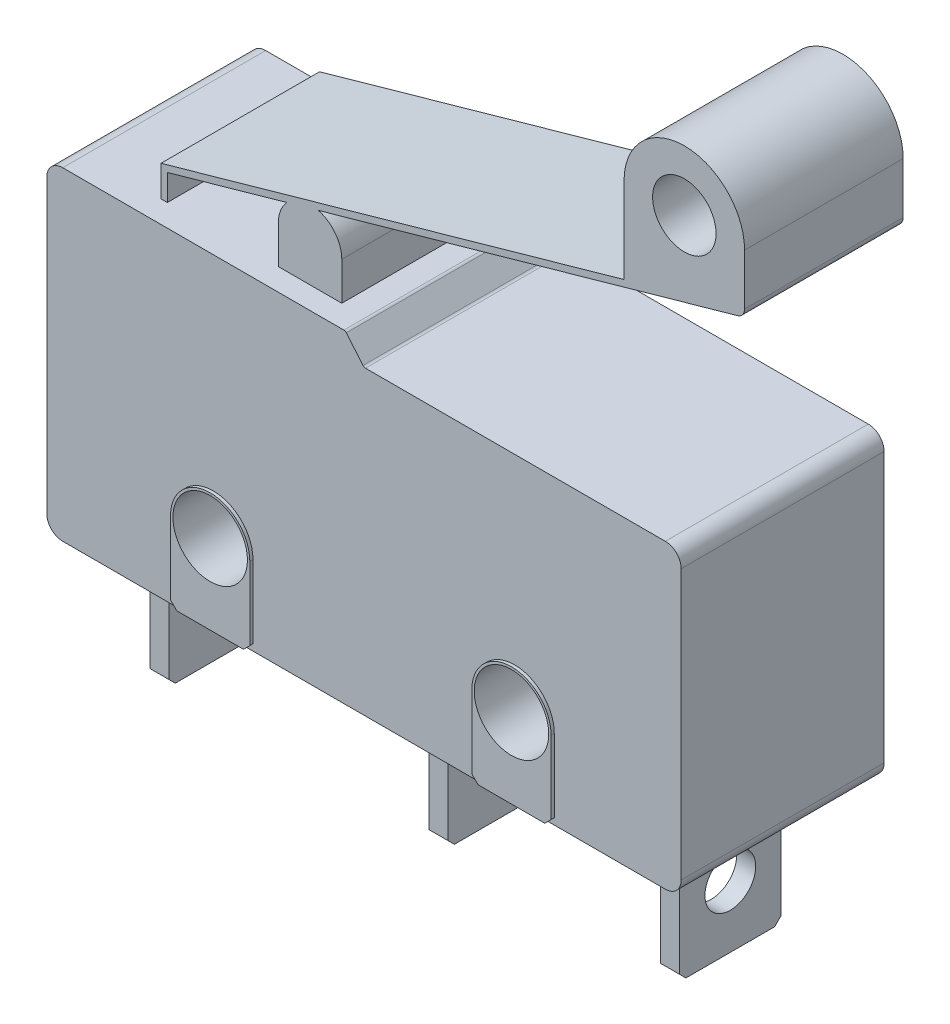
from build123d import *

# Parameters (mm, degrees)
SKETCH_1_W               = 20
SKETCH_1_H               = 10.2
SKETCH_1_R               = 1.175
EXTRUDE_1_DEPTH          = 6.4
CUT_EXTRUDE_1_DEPTH      = 1
CUT_EXTRUDE_1_DEPTH_BACK = 7.4
FILLET_1_R               = 0.1
FILLET_2_R               = 0.5
SKETCH_8_R               = 1.175
EXTRUDE_5_DEPTH          = 0.1
CHAMFER_1_SIZE           = 0.2
SKETCH_3_W               = 0.6
SKETCH_3_H               = 3.9
EXTRUDE_2_DEPTH          = 1.6
SKETCH_9_R               = 0.8
CUT_EXTRUDE_2_DEPTH      = 19.35
CHAMFER_2_SIZE           = 0.2
SKETCH_5_R               = 1
EXTRUDE_3_DEPTH          = 2.5
EXTRUDE_6_DEPTH          = 2.5
FILLET_3_R               = 0.3


with BuildPart() as part:
    # 草图1 → 凸台-拉伸1 (new body)
    with BuildSketch(Plane.XY):
        with Locations((10, 5.1)):
            Rectangle(SKETCH_1_W, SKETCH_1_H)
        with Locations((5.25, 2.5)):
            Circle(SKETCH_1_R, mode=Mode.SUBTRACT)
        with Locations((14.75, 2.5)):
            Circle(SKETCH_1_R, mode=Mode.SUBTRACT)
    extrude(amount=EXTRUDE_1_DEPTH)

    # 草图7 → 切除-拉伸1 (cut, two sides)
    with BuildSketch(Plane.XY.offset(6.4)) as cut_extrude_1_sk:
        Polygon((20, 9.5), (10, 9.5), (9.412630258, 10.2), (20, 10.2), align=None)
    extrude(amount=CUT_EXTRUDE_1_DEPTH, mode=Mode.SUBTRACT)
    extrude(cut_extrude_1_sk.sketch, amount=-CUT_EXTRUDE_1_DEPTH_BACK, mode=Mode.SUBTRACT)

    # 圆角1
    fillet_1_edges = [part.edges().sort_by_distance(p)[0] for p in [
        (9.412630258, 10.2, 3.2),
        (10, 9.5, 3.2),
    ]]
    fillet(fillet_1_edges, radius=FILLET_1_R)

    # 圆角2
    fillet_2_edges = [part.edges().sort_by_distance(p)[0] for p in [
        (20, 9.5, 3.2),
        (0, 10.2, 3.2),
        (20, 0, 3.2),
        (0, 0, 3.2),
    ]]
    fillet(fillet_2_edges, radius=FILLET_2_R)

    # 草图8 → 凸台-拉伸5 (add)
    with BuildSketch(Plane.XY.offset(6.4)):
        with BuildLine():
            Line((4, 2.5), (4, 0))
            Line((4, 0), (6.5, 0))
            Line((6.5, 0), (6.5, 2.5))
            ThreePointArc((6.5, 2.5), (5.25, 3.75), (4, 2.5))
        make_face()
        with Locations((5.25, 2.5)):
            Circle(SKETCH_8_R, mode=Mode.SUBTRACT)
        with BuildLine():
            Line((13.5, 2.5), (13.5, 0))
            Line((13.5, 0), (16, 0))
            Line((16, 0), (16, 2.5))
            ThreePointArc((16, 2.5), (14.75, 3.75), (13.5, 2.5))
        make_face()
        with Locations((14.75, 2.5)):
            Circle(SKETCH_8_R, mode=Mode.SUBTRACT)
    extrude_5 = extrude(amount=EXTRUDE_5_DEPTH)

    # 镜向1: 凸台-拉伸5 across plane
    add(extrude_5.mirror(Plane.XY.offset(3.2)))

    # 倒角1
    chamfer_1_edges = [part.edges().sort_by_distance(p)[0] for p in [
        (6.5, 0, -0.05),
        (4, 0, -0.05),
        (16, 0, -0.05),
        (13.5, 0, -0.05),
        (4, 0, 6.45),
        (6.5, 0, 6.45),
        (13.5, 0, 6.45),
        (16, 0, 6.45),
    ]]
    chamfer(chamfer_1_edges, length=CHAMFER_1_SIZE)

    # 草图3 → 凸台-拉伸2 (add, symmetric)
    with BuildSketch(Plane.XY.offset(3.2)):
        with Locations((1.95, -1.95)):
            Rectangle(SKETCH_3_W, SKETCH_3_H)
        with Locations((10.75, -1.95)):
            Rectangle(SKETCH_3_W, SKETCH_3_H)
        with Locations((18.05, -1.95)):
            Rectangle(SKETCH_3_W, SKETCH_3_H)
    extrude(amount=EXTRUDE_2_DEPTH, both=True)

    # 草图9 → 切除-拉伸2 (cut, through all)
    with BuildSketch(Plane.ZY.offset(-1.65)):
        with Locations((3.2, -1.95)):
            Circle(SKETCH_9_R)
    extrude(amount=-CUT_EXTRUDE_2_DEPTH, mode=Mode.SUBTRACT)

    # 倒角2
    chamfer_2_edges = [part.edges().sort_by_distance(p)[0] for p in [
        (1.95, -3.9, 1.6),
        (1.95, -3.9, 4.8),
        (10.75, -3.9, 1.6),
        (10.75, -3.9, 4.8),
        (18.05, -3.9, 1.6),
        (18.05, -3.9, 4.8),
    ]]
    chamfer(chamfer_2_edges, length=CHAMFER_2_SIZE)



with BuildPart() as body_2:
    # 草图5 → 凸台-拉伸3 (new body, symmetric)
    with BuildSketch(Plane.XY.offset(3.2)):
        with BuildLine():
            Line((21.3, 18), (21.3, 16.267087306))
            Line((21.3, 16.267087306), (21.3, 16.163171396))
            Line((21.3, 16.163171396), (3.1, 11.020209549))
            Line((3.1, 11.020209549), (3.1, 10.193829773))
            Line((3.1, 10.193829773), (2.9, 10.2))
            Line((2.9, 10.2), (2.9, 11.171525305))
            Line((2.9, 11.171525305), (17.5, 15.297197995))
            Line((17.5, 15.297197995), (17.5, 18))
            ThreePointArc((17.5, 18), (19.4, 19.9), (21.3, 18))
        make_face()
        with Locations((19.4, 18)):
            Circle(SKETCH_5_R, mode=Mode.SUBTRACT)
    extrude(amount=EXTRUDE_3_DEPTH, both=True)


with BuildPart() as part_1:
    add(part.part)

    add(body_2.part)  # 凸台-拉伸6 merges body 2
    # 草图10 → 凸台-拉伸6 (add, symmetric)
    with BuildSketch(Plane.XY.offset(3.2)):
        with BuildLine():
            Line((6.6, 11.4), (6.6, 10.2))
            Line((6.6, 10.2), (8.6, 10.2))
            Line((8.6, 10.2), (8.6, 11.4))
            ThreePointArc((8.6, 11.4), (7.6, 12.4), (6.6, 11.4))
        make_face()
    extrude(amount=EXTRUDE_6_DEPTH, both=True)

    # 圆角3
    fillet_3_edges = [part_1.edges().sort_by_distance(p)[0] for p in [
        (21.3, 16.163171396, 3.2),
    ]]
    fillet(fillet_3_edges, radius=FILLET_3_R)


solid = part_1.part
